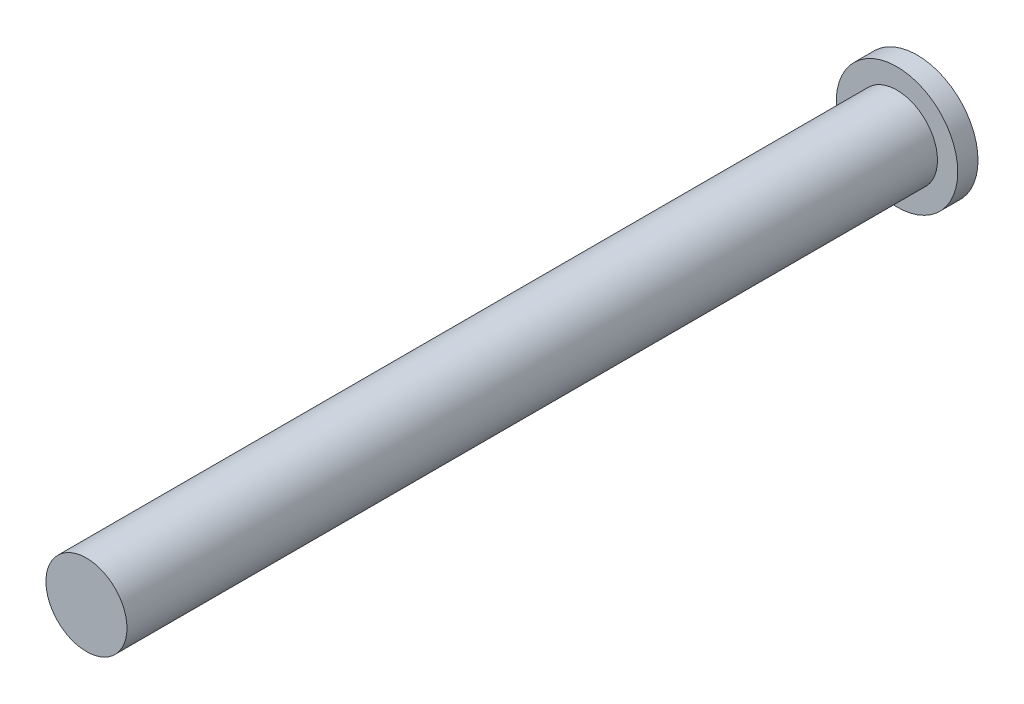
from build123d import *

# Parameters (mm, degrees)
ESQUISSE1_R        = 2
BOSS_EXTRU_1_DEPTH = 40
ESQUISSE1_3_R      = 3
BOSS_EXTRU_2_DEPTH = 1


with BuildPart() as part:
    # Esquisse1 → Boss.-Extru.1 (new body)
    with BuildSketch(Plane.XY):
        Circle(ESQUISSE1_R)
    extrude(amount=BOSS_EXTRU_1_DEPTH)

    # Esquisse1_3 → Boss.-Extru.2 (add)
    with BuildSketch(Plane.XY):
        Circle(ESQUISSE1_3_R)
    extrude(amount=-BOSS_EXTRU_2_DEPTH)


solid = part.part
